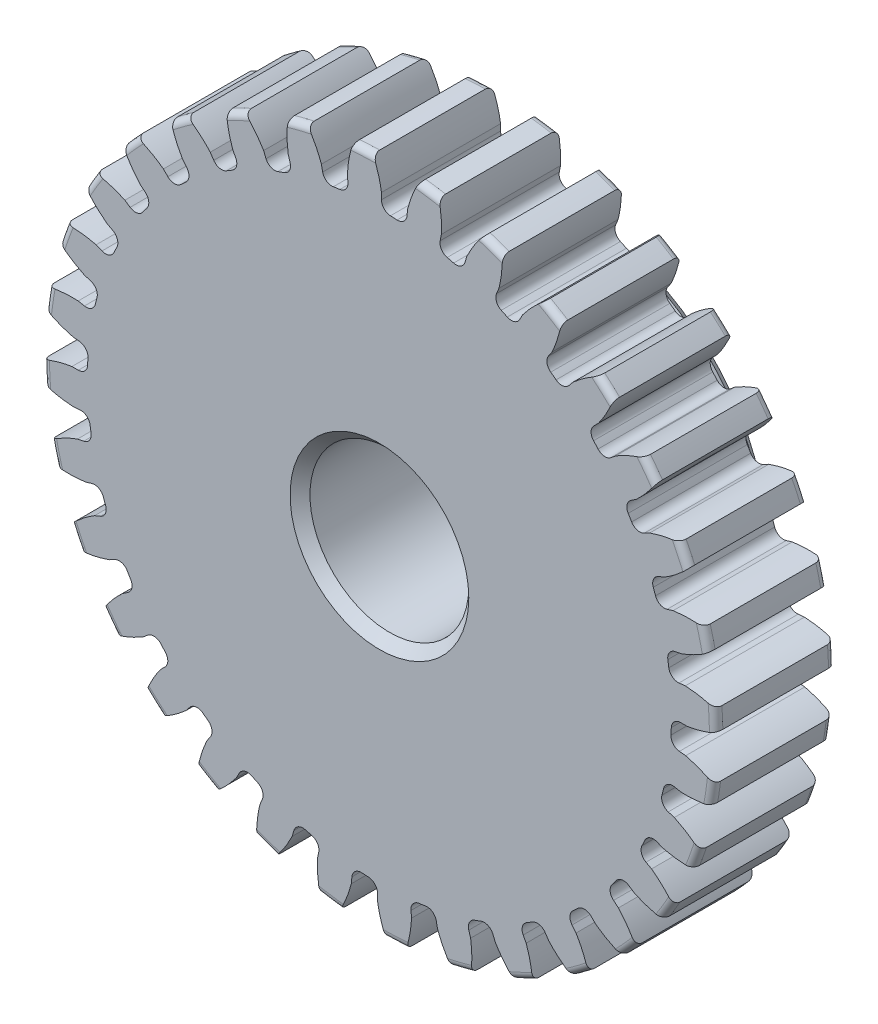
from build123d import *

# Parameters (mm, degrees)
SKETCH1_R                = 13.462
BOSS_EXTRUDE1_DEPTH      = 4.7625
SKETCH2_W                = 3.175
SKETCH2_H                = 7.9375
FILLET2_R                = 0.26924
CUT_EXTRUDE1_DEPTH       = 8.9375
FILLET1_R                = 0.37404675
CIRPATTERN1_COUNT        = 32
FILLET1_OF_CIRPATTERN1_R = 0.37404675
SKETCH5_R                = 3.175
CUT_EXTRUDE2_DEPTH       = 8.9375
CHAMFER1_SIZE            = 0.396875


with BuildPart() as part:
    # Sketch1 → Boss-Extrude1 (new body)
    with BuildSketch(Plane.XY):
        Circle(SKETCH1_R)
    extrude(amount=-BOSS_EXTRUDE1_DEPTH)

    # Sketch2 → Revolve1 (revolve)
    with BuildSketch(Plane(origin=(0, 0, 0), x_dir=(0, 0, -1), z_dir=(1, 0, 0))):
        with Locations((6.35, 3.96875)):
            Rectangle(SKETCH2_W, SKETCH2_H)
    revolve(axis=Axis((0, 0, -4.7625), (0, 0, -1)))

    # Fillet2
    fillet2_edges = [part.edges().sort_by_distance(p)[0] for p in [
        (-13.462, 0, 0),
        (-13.462, 0, -4.7625),
        (0, -7.9375, -4.7625),
    ]]
    fillet(fillet2_edges, radius=FILLET2_R)

    # Sketch4 → Cut-Extrude1 (cut, through all)
    with BuildSketch(Plane.XY):
        with BuildLine():
            Line((0.079822856, 12.295215923), (0.079822856, 11.675789644))
            ThreePointArc((0.079822856, 11.675789644), (0.572918571, 11.661998106), (1.064991695, 11.627391289))
            Line((1.064991695, 11.627391289), (1.125706229, 12.243834847))
            add(Edge.make_bspline(
                [(2.722348689, 14.732391365), (1.492203534, 13.686801954), (1.125706229, 12.243834847)],
                knots=[0, 0, 0, 1, 1, 1], degree=2))
            ThreePointArc((2.722348689, 14.732391365), (0.735124139, 14.963760564), (-1.265209537, 14.928287997))
            add(Edge.make_bspline(
                [(-1.265209537, 14.928287997), (-0.143473818, 13.767157818), (0.079822856, 12.295215923)],
                knots=[0, 0, 0, 1, 1, 1], degree=2))
        make_face()
    cut_extrude1 = extrude(amount=-CUT_EXTRUDE1_DEPTH, mode=Mode.SUBTRACT)

    # Fillet1
    fillet1_edges = [part.edges().sort_by_distance(p)[0] for p in [
        (1.064991695, 11.627391289, -2.38125),
        (0.079822856, 11.675789644, -2.38125),
    ]]
    fillet(fillet1_edges, radius=FILLET1_R)

    # CirPattern1: Cut-Extrude1 ×32 about axis
    cirpattern1_axis = Axis((0, 0, -4.7625), (0, 0, 1))
    for i in range(1, CIRPATTERN1_COUNT):
        add(cut_extrude1.rotate(cirpattern1_axis, i * 360 / CIRPATTERN1_COUNT), mode=Mode.SUBTRACT)

    # Fillet1 of CirPattern1
    fillet1_of_cirpattern1_edges = [part.edges().sort_by_distance(p)[0] for p in [
        (-1.223863333, 11.611743799, -2.38125),
        (-2.19954448, 11.467015287, -2.38125),
        (-3.465685979, 11.149863506, -2.38125),
        (-4.394384554, 10.817569963, -2.38125),
        (-5.574324256, 10.259500211, -2.38125),
        (-6.420350895, 9.752411491, -2.38125),
        (-7.468744379, 8.974870077, -2.38125),
        (-8.199586751, 8.312473316, -2.38125),
        (-9.076144843, 7.34534072, -2.38125),
        (-9.663717086, 6.553091452, -2.38125),
        (-10.334754151, 5.433534037, -2.38125),
        (-10.756476194, 4.541877959, -2.38125),
        (-11.196204653, 3.312919689, -2.38125),
        (-11.435869954, 2.356122643, -2.38125),
        (-11.627391289, 1.064991695, -2.38125),
        (-11.675789644, 0.079822856, -2.38125),
        (-11.611743799, -1.223863333, -2.38125),
        (-11.467015287, -2.19954448, -2.38125),
        (-11.149863506, -3.465685979, -2.38125),
        (-10.817569963, -4.394384554, -2.38125),
        (-10.259500211, -5.574324256, -2.38125),
        (-9.752411491, -6.420350895, -2.38125),
        (-8.974870077, -7.468744379, -2.38125),
        (-8.312473316, -8.199586751, -2.38125),
        (-7.34534072, -9.076144843, -2.38125),
        (-6.553091452, -9.663717086, -2.38125),
        (-5.433534037, -10.334754151, -2.38125),
        (-4.541877959, -10.756476194, -2.38125),
        (-3.312919689, -11.196204653, -2.38125),
        (-2.356122643, -11.435869954, -2.38125),
        (-1.064991695, -11.627391289, -2.38125),
        (-0.079822856, -11.675789644, -2.38125),
        (1.223863333, -11.611743799, -2.38125),
        (2.19954448, -11.467015287, -2.38125),
        (3.465685979, -11.149863506, -2.38125),
        (4.394384554, -10.817569963, -2.38125),
        (5.574324256, -10.259500211, -2.38125),
        (6.420350895, -9.752411491, -2.38125),
        (7.468744379, -8.974870077, -2.38125),
        (8.199586751, -8.312473316, -2.38125),
        (9.076144843, -7.34534072, -2.38125),
        (9.663717086, -6.553091452, -2.38125),
        (10.334754151, -5.433534037, -2.38125),
        (10.756476194, -4.541877959, -2.38125),
        (11.196204653, -3.312919689, -2.38125),
        (11.435869954, -2.356122643, -2.38125),
        (11.627391289, -1.064991695, -2.38125),
        (11.675789644, -0.079822856, -2.38125),
        (11.611743799, 1.223863333, -2.38125),
        (11.467015287, 2.19954448, -2.38125),
        (11.149863506, 3.465685979, -2.38125),
        (10.817569963, 4.394384554, -2.38125),
        (10.259500211, 5.574324256, -2.38125),
        (9.752411491, 6.420350895, -2.38125),
        (8.974870077, 7.468744379, -2.38125),
        (8.312473316, 8.199586751, -2.38125),
        (7.34534072, 9.076144843, -2.38125),
        (6.553091452, 9.663717086, -2.38125),
        (5.433534037, 10.334754151, -2.38125),
        (4.541877959, 10.756476194, -2.38125),
        (3.312919689, 11.196204653, -2.38125),
        (2.356122643, 11.435869954, -2.38125),
    ]]
    fillet(fillet1_of_cirpattern1_edges, radius=FILLET1_OF_CIRPATTERN1_R)

    # Sketch5 → Cut-Extrude2 (cut, through all)
    with BuildSketch(Plane.XY):
        Circle(SKETCH5_R)
    extrude(amount=-CUT_EXTRUDE2_DEPTH, mode=Mode.SUBTRACT)

    # Chamfer1
    chamfer1_edges = [part.edges().sort_by_distance(p)[0] for p in [
        (-3.175, 0, -7.9375),
        (-3.175, 0, 0),
        (0, -7.9375, -7.9375),
    ]]
    chamfer(chamfer1_edges, length=CHAMFER1_SIZE)


solid = part.part
